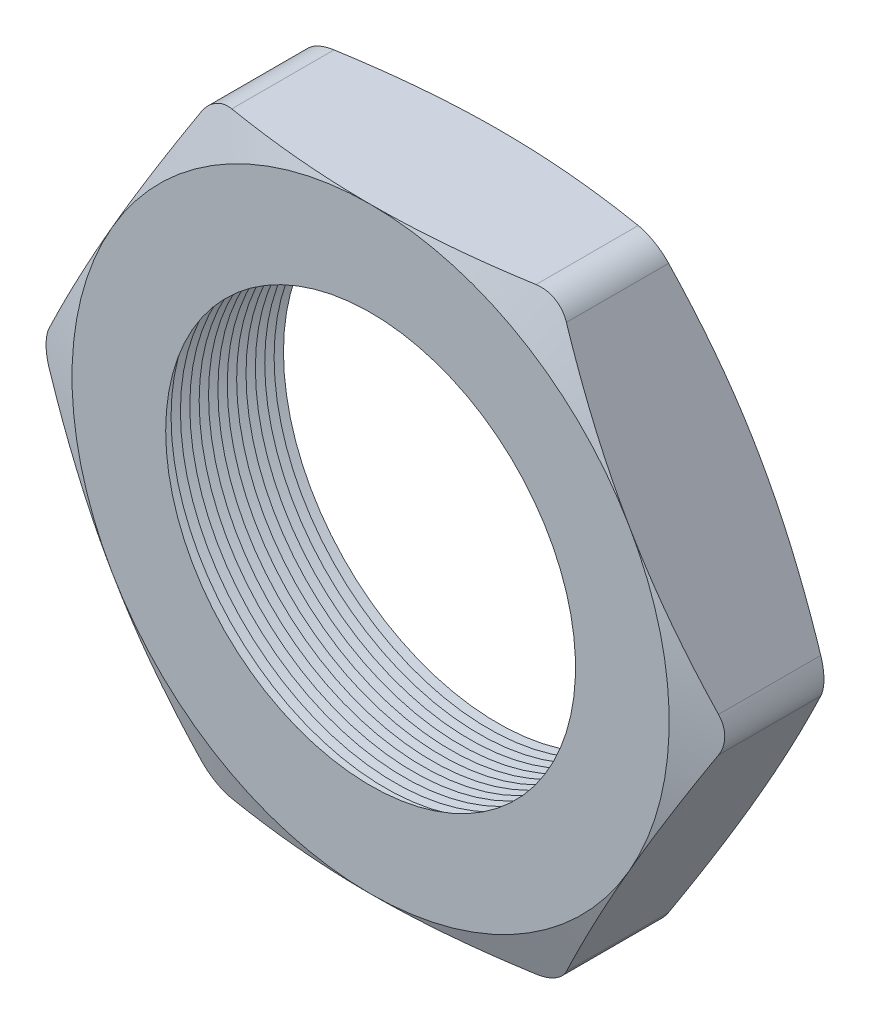
from build123d import *

# Parameters (mm, degrees)
SKETCH1_R          = 4.445
EXTRUDE1_DEPTH     = 2.794
FILLET1_R          = 0.762
SKETCH2_OUTSIDE_W  = 41.532
SKETCH2_OUTSIDE_H  = 39.764
SKETCH2_OUTSIDE_R  = 6.477
CUT_EXTRUDE1_DEPTH = 3.794
CUT_EXTRUDE1_DRAFT = -70
SKETCH3_OUTSIDE_W  = 41.532
SKETCH3_OUTSIDE_H  = 39.764
SKETCH3_OUTSIDE_R  = 6.477
CUT_EXTRUDE2_DEPTH = 3.7940001
CUT_EXTRUDE2_DRAFT = -70
LPATTERN1_COUNT    = 14
LPATTERN1_PITCH    = 0.2032


with BuildPart() as part:
    # Sketch1 → Extrude1 (new body)
    with BuildSketch(Plane.XY):
        Polygon((-7.478995387, 0), (-3.739497694, -6.477), (3.739497694, -6.477), (7.478995387, 0), (3.739497694, 6.477), (-3.739497694, 6.477), align=None)
        Circle(SKETCH1_R, mode=Mode.SUBTRACT)
    extrude(amount=EXTRUDE1_DEPTH)

    # Fillet1
    fillet1_edges = [part.edges().sort_by_distance(p)[0] for p in [
        (7.478995387, 0, 1.397),
        (3.739497694, -6.477, 1.397),
        (-3.739497694, -6.477, 1.397),
        (-7.478995387, 0, 1.397),
        (-3.739497694, 6.477, 1.397),
        (3.739497694, 6.477, 1.397),
    ]]
    fillet(fillet1_edges, radius=FILLET1_R)


with BuildPart() as cut_extrude1_tool:
    # Sketch2 outside → Cut-Extrude1 (with draft: the straight prism first)
    with BuildSketch(Plane.XY.offset(2.794)):
        Rectangle(SKETCH2_OUTSIDE_W, SKETCH2_OUTSIDE_H)
        Circle(SKETCH2_OUTSIDE_R, mode=Mode.SUBTRACT)
    extrude(amount=-CUT_EXTRUDE1_DEPTH)
    # Cut-Extrude1: the draft: its side faces are tilted about the plane it starts from
    cut_extrude1_sides = [cut_extrude1_tool.faces().sort_by_distance(p)[0] for p in [
        (0, -19.882, 0.897),
        (20.766, 0, 0.897),
        (0, 19.882, 0.897),
        (-20.766, 0, 0.897),
        (-6.477, 0, 0.897),
    ]]
    draft(cut_extrude1_sides, Plane.XY.offset(2.794), CUT_EXTRUDE1_DRAFT)


with BuildPart() as part_1:
    add(part.part)

    # Cut-Extrude1: cut by cut_extrude1_tool
    add(cut_extrude1_tool.part, mode=Mode.SUBTRACT)


with BuildPart() as cut_extrude2_tool:
    # Sketch3 outside → Cut-Extrude2 (with draft: the straight prism first)
    with BuildSketch(Plane(origin=(0, 0, 0), x_dir=(-1, 0, 0), z_dir=(0, 0, -1))):
        Rectangle(SKETCH3_OUTSIDE_W, SKETCH3_OUTSIDE_H)
        Circle(SKETCH3_OUTSIDE_R, mode=Mode.SUBTRACT)
    extrude(amount=-CUT_EXTRUDE2_DEPTH)
    # Cut-Extrude2: the draft: its side faces are tilted about the plane it starts from
    cut_extrude2_sides = [cut_extrude2_tool.faces().sort_by_distance(p)[0] for p in [
        (0, -19.882, 1.89700005),
        (-20.766, 0, 1.89700005),
        (0, 19.882, 1.89700005),
        (20.766, 0, 1.89700005),
        (6.477, 0, 1.89700005),
    ]]
    draft(cut_extrude2_sides, Plane(origin=(0, 0, 0), x_dir=(-1, 0, 0), z_dir=(0, 0, -1)), CUT_EXTRUDE2_DRAFT)


with BuildPart() as part_2:
    add(part_1.part)

    # Cut-Extrude2: cut by cut_extrude2_tool
    add(cut_extrude2_tool.part, mode=Mode.SUBTRACT)

    # Sketch4 → Cut-Revolve1 (revolve, cut)
    with BuildSketch(Plane(origin=(0, 0, 0), x_dir=(1, 0, 0), z_dir=(0, 1, 0))):
        Polygon((-4.445, -2.794), (-4.445, -2.354059095), (-4.826, -2.574029547), align=None)
    cut_revolve1 = revolve(axis=Axis((0, 0, 2.794), (0, 0, -1)), mode=Mode.SUBTRACT)

    # LPattern1: Cut-Revolve1 ×14
    with Locations(*[(0, 0, -i * LPATTERN1_PITCH) for i in range(1, LPATTERN1_COUNT)]):
        add(cut_revolve1, mode=Mode.SUBTRACT)


solid = part_2.part
